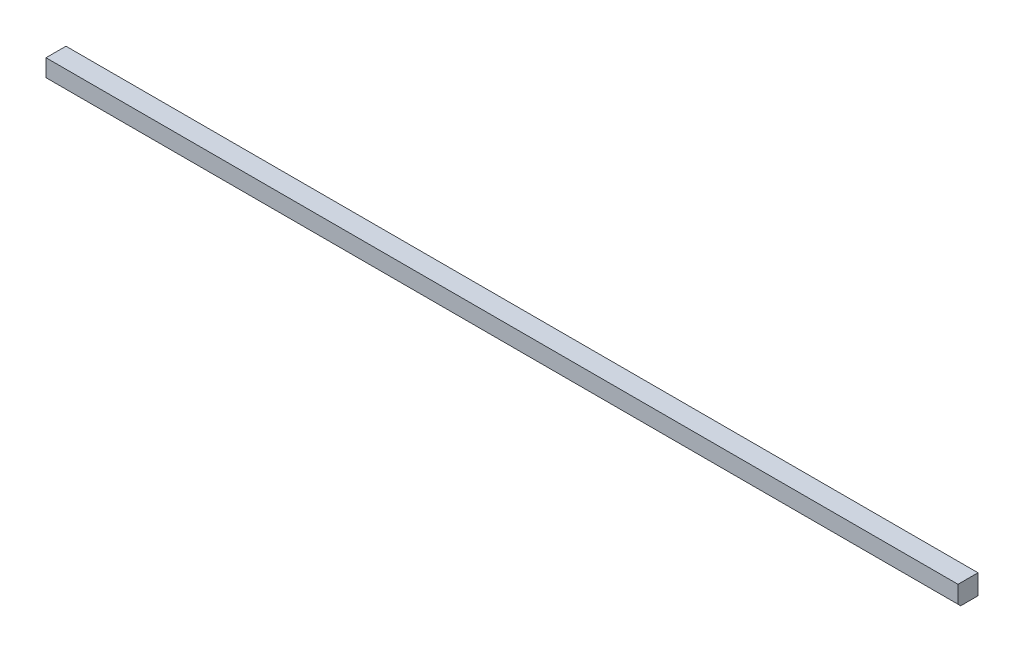
from build123d import *

# Parameters (mm, degrees)
SKETCH1_W           = 869.95
SKETCH1_H           = 19.05
BOSS_EXTRUDE1_DEPTH = 19.05
CHAMFER1_SIZE       = 2.54


with BuildPart() as part:
    # Sketch1 → Boss-Extrude1 (new body)
    with BuildSketch(Plane(origin=(0, 0, 0), x_dir=(1, 0, 0), z_dir=(0, 1, 0))):
        with Locations((434.975, 9.525)):
            Rectangle(SKETCH1_W, SKETCH1_H)
    extrude(amount=BOSS_EXTRUDE1_DEPTH)

    # Chamfer1
    chamfer1_edges = [part.edges().sort_by_distance(p)[0] for p in [
        (434.975, 0, 0),
    ]]
    chamfer(chamfer1_edges, length=CHAMFER1_SIZE)


solid = part.part
